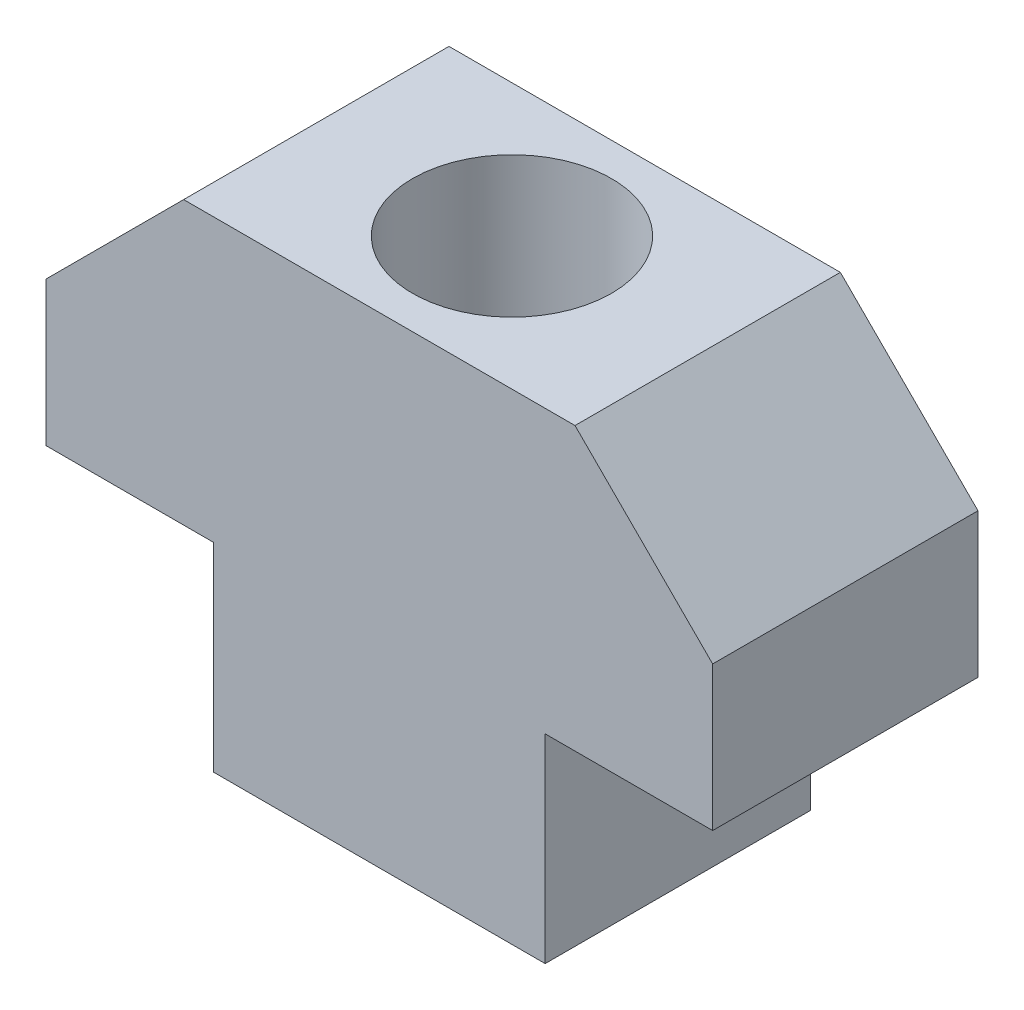
from build123d import *

# Parameters (mm, degrees)
EXTRUDE1_DEPTH     = 4
CUT_EXTRUDE1_REACH = 16.5
SKETCH2_R          = 3


with BuildPart() as part:
    # Sketch1 → Extrude1 (new body, symmetric)
    with BuildSketch(Plane.XY):
        Polygon((-5, 0), (5, 0), (5, 6), (10.05, 6), (10.05, 10.35), (5.9, 14.5), (-5.9, 14.5), (-10.05, 10.35), (-10.05, 6), (-5, 6), align=None)
    extrude(amount=EXTRUDE1_DEPTH, both=True)

    # Sketch2 → Cut-Extrude1 (cut, up to next)
    with BuildSketch(Plane(origin=(0, 0, 0), x_dir=(1, 0, 0), z_dir=(0, 1, 0)), mode=Mode.PRIVATE) as cut_extrude1_sk1:
        Circle(SKETCH2_R)
    cut_extrude1_tool1 = extrude(cut_extrude1_sk1.sketch, amount=CUT_EXTRUDE1_REACH, mode=Mode.PRIVATE) & part.part
    add(cut_extrude1_tool1.solids().sort_by_distance((0, 0, 0))[0], mode=Mode.SUBTRACT)


solid = part.part
